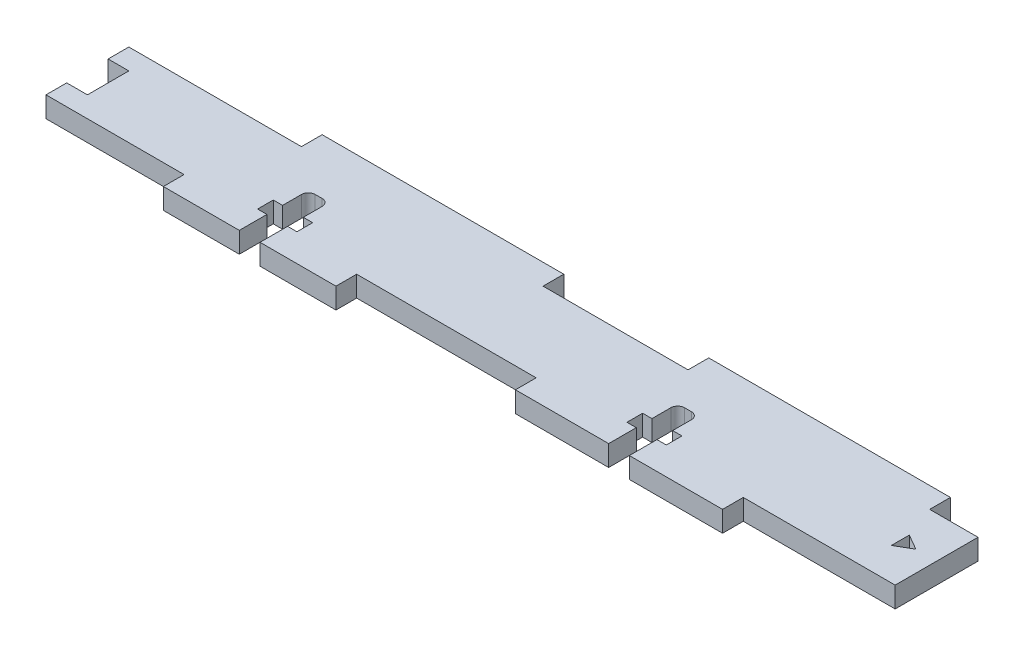
from build123d import *

# Parameters (mm, degrees)
SKETCH1_W                = 123
SKETCH1_H                = 12
BOSS_EXTRUDE1_DEPTH      = 1.5
SKETCH2_W                = 30
SKETCH2_H                = 3
BOSS_EXTRUDE2_DEPTH      = 1.5
SKETCH12_W               = 25
SKETCH12_H               = 3
BOSS_EXTRUDE3_DEPTH      = 1.5
CUT_EXTRUDE8_DEPTH       = 2.5
CUT_EXTRUDE8_DEPTH_BACK  = 2.5
SKETCH13_W               = 35
SKETCH13_H               = 3
BOSS_EXTRUDE4_DEPTH      = 1.5
CUT_EXTRUDE10_DEPTH      = 2.5
CUT_EXTRUDE10_DEPTH_BACK = 2.5
SKETCH16_W               = 3
SKETCH16_H               = 6
CUT_EXTRUDE11_DEPTH      = 2.5
CUT_EXTRUDE11_DEPTH_BACK = 2.5


with BuildPart() as part:
    # Sketch1 → Boss-Extrude1 (new body, symmetric)
    with BuildSketch(Plane(origin=(0, 0, 0), x_dir=(1, 0, 0), z_dir=(0, 1, 0))):
        Rectangle(SKETCH1_W, SKETCH1_H)
    extrude(amount=BOSS_EXTRUDE1_DEPTH, both=True)

    # Sketch2 → Boss-Extrude2 (add, symmetric)
    with BuildSketch(Plane(origin=(0, 0, 0), x_dir=(1, 0, 0), z_dir=(0, 1, 0))):
        with Locations((24.5, -7.5)):
            Rectangle(SKETCH2_W, SKETCH2_H)
    extrude(amount=BOSS_EXTRUDE2_DEPTH, both=True)

    # Sketch12 → Boss-Extrude3 (add, symmetric)
    with BuildSketch(Plane(origin=(0, 0, 0), x_dir=(1, 0, 0), z_dir=(0, 1, 0))):
        with Locations((-29, -7.5)):
            Rectangle(SKETCH12_W, SKETCH12_H)
    extrude(amount=BOSS_EXTRUDE3_DEPTH, both=True)

    # Sketch11 → Cut-Extrude8 (cut, two sides)
    with BuildSketch(Plane(origin=(0, 0, 0), x_dir=(1, 0, 0), z_dir=(0, 1, 0))) as cut_extrude8_sk:
        with BuildLine():
            Line((-30.5, -9), (-27.5, -9))
            Line((-27.5, -9), (-27.5, -5))
            Line((-27.5, -5), (-26.15, -5))
            Line((-26.15, -5), (-26.15, -2.73))
            Line((-26.15, -2.73), (-27.5, -2.73))
            Line((-27.5, -2.73), (-27.5, 0))
            ThreePointArc((-27.5, 0), (-27.792893219, 0.707106781), (-28.5, 1))
            Line((-28.5, 1), (-29.5, 1))
            ThreePointArc((-29.5, 1), (-30.207106781, 0.707106781), (-30.5, 0))
            Line((-30.5, 0), (-30.5, -2.73))
            Line((-30.5, -2.73), (-31.85, -2.73))
            Line((-31.85, -2.73), (-31.85, -5))
            Line((-31.85, -5), (-30.5, -5))
            Line((-30.5, -5), (-30.5, -9))
        make_face()
        with BuildLine():
            Line((23, -9), (26, -9))
            Line((26, -9), (26, -5))
            Line((26, -5), (27.35, -5))
            Line((27.35, -5), (27.35, -2.73))
            Line((27.35, -2.73), (26, -2.73))
            Line((26, -2.73), (26, 0))
            ThreePointArc((26, 0), (25.707106781, 0.707106781), (25, 1))
            Line((25, 1), (24, 1))
            ThreePointArc((24, 1), (23.292893219, 0.707106781), (23, 0))
            Line((23, 0), (23, -2.73))
            Line((23, -2.73), (21.65, -2.73))
            Line((21.65, -2.73), (21.65, -5))
            Line((21.65, -5), (23, -5))
            Line((23, -5), (23, -9))
        make_face()
    extrude(amount=CUT_EXTRUDE8_DEPTH, mode=Mode.SUBTRACT)
    extrude(cut_extrude8_sk.sketch, amount=-CUT_EXTRUDE8_DEPTH_BACK, mode=Mode.SUBTRACT)

    # Sketch13 → Boss-Extrude4 (add, symmetric)
    with BuildSketch(Plane(origin=(0, 0, 0), x_dir=(1, 0, 0), z_dir=(0, 1, 0))):
        with Locations((-19, 7.5)):
            Rectangle(SKETCH13_W, SKETCH13_H)
        with Locations((37, 7.5)):
            Rectangle(SKETCH13_W, SKETCH13_H)
    extrude(amount=BOSS_EXTRUDE4_DEPTH, both=True)

    # Sketch15 → Cut-Extrude10 (cut, two sides)
    with BuildSketch(Plane(origin=(0, 0, 0), x_dir=(1, 0, 0), z_dir=(0, 1, 0))) as cut_extrude10_sk:
        Polygon((56.25, -1.299038106), (58.5, 0), (56.25, 1.299038106), align=None)
    extrude(amount=CUT_EXTRUDE10_DEPTH, mode=Mode.SUBTRACT)
    extrude(cut_extrude10_sk.sketch, amount=-CUT_EXTRUDE10_DEPTH_BACK, mode=Mode.SUBTRACT)

    # Sketch16 → Cut-Extrude11 (cut, two sides)
    with BuildSketch(Plane(origin=(0, 0, 0), x_dir=(1, 0, 0), z_dir=(0, 1, 0))) as cut_extrude11_sk:
        with Locations((-60, 0)):
            Rectangle(SKETCH16_W, SKETCH16_H)
    extrude(amount=CUT_EXTRUDE11_DEPTH, mode=Mode.SUBTRACT)
    extrude(cut_extrude11_sk.sketch, amount=-CUT_EXTRUDE11_DEPTH_BACK, mode=Mode.SUBTRACT)


solid = part.part
